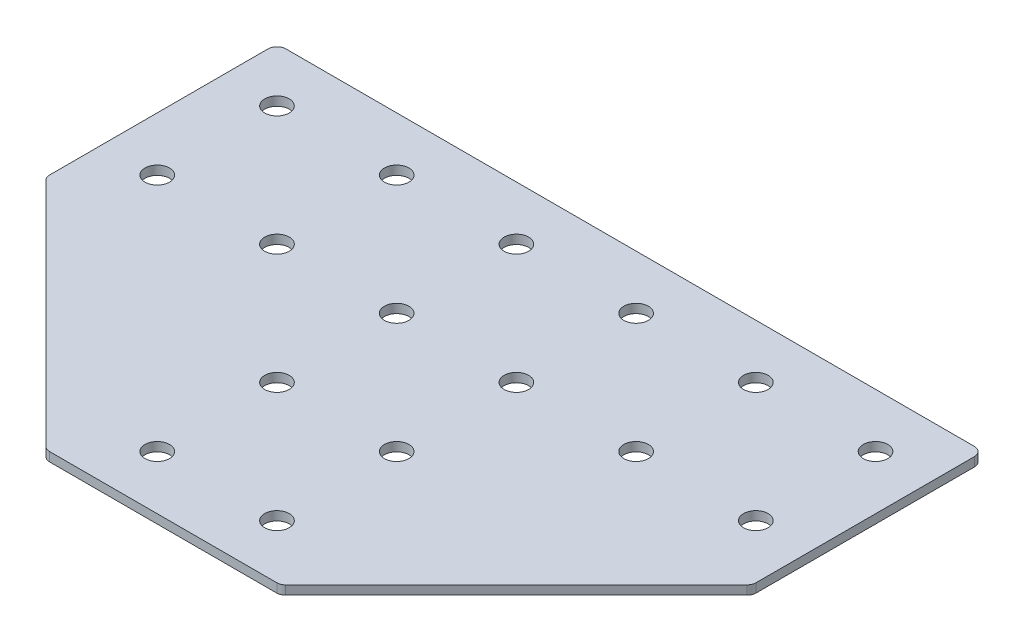
from build123d import *

# Parameters (mm, degrees)
SKETCH_1_R      = 4.1
EXTRUDE_1_DEPTH = 3


with BuildPart() as part:
    # Эскиз1 → Бобышка-Вытянуть1 (new body)
    with BuildSketch(Plane.XZ.offset(-0.99134831)):
        with BuildLine():
            Line((36.958930758, 76.479058001), (-38.898933619, 76.479058001))
            ThreePointArc((-38.898933619, 76.479058001), (-40.046983916, 76.250696599), (-41.020253962, 75.600378345))
            Line((-41.020253962, 75.600378345), (-118.091321774, -1.470689467))
            ThreePointArc((-118.091321774, -1.470689467), (-118.741640028, -2.443959513), (-118.970001431, -3.592009811))
            Line((-118.970001431, -3.592009811), (-118.970001431, -76.520941999))
            ThreePointArc((-118.970001431, -76.520941999), (-118.091321774, -78.642262342), (-115.970001431, -79.520941999))
            Line((-115.970001431, -79.520941999), (114.029998569, -79.520941999))
            ThreePointArc((114.029998569, -79.520941999), (116.151318913, -78.642262342), (117.029998569, -76.520941999))
            Line((117.029998569, -76.520941999), (117.029998569, -3.592009811))
            ThreePointArc((117.029998569, -3.592009811), (116.801637167, -2.443959513), (116.151318913, -1.470689467))
            Line((116.151318913, -1.470689467), (39.080251101, 75.600378345))
            ThreePointArc((39.080251101, 75.600378345), (38.106981055, 76.250696599), (36.958930758, 76.479058001))
        make_face()
        with Locations(Location((99.029998569, -21.520941999, 0), (0, 0, 90))):  # turned: the seam where the file's is
            Circle(SKETCH_1_R, mode=Mode.SUBTRACT)
        with Locations(Location((59.029998569, -21.520941999, 0), (0, 0, 90))):  # turned: the seam where the file's is
            Circle(SKETCH_1_R, mode=Mode.SUBTRACT)
        with Locations(Location((19.029998569, 58.479058001, 0), (0, 0, 90))):  # turned: the seam where the file's is
            Circle(SKETCH_1_R, mode=Mode.SUBTRACT)
        with Locations(Location((19.029998569, 18.479058001, 0), (0, 0, 90))):  # turned: the seam where the file's is
            Circle(SKETCH_1_R, mode=Mode.SUBTRACT)
        with Locations(Location((19.029998569, -21.520941999, 0), (0, 0, 90))):  # turned: the seam where the file's is
            Circle(SKETCH_1_R, mode=Mode.SUBTRACT)
        with Locations(Location((99.029998569, -61.520941999, 0), (0, 0, 90))):  # turned: the seam where the file's is
            Circle(SKETCH_1_R, mode=Mode.SUBTRACT)
        with Locations(Location((59.029998569, -61.520941999, 0), (0, 0, 90))):  # turned: the seam where the file's is
            Circle(SKETCH_1_R, mode=Mode.SUBTRACT)
        with Locations(Location((19.029998569, -61.520941999, 0), (0, 0, 90))):  # turned: the seam where the file's is
            Circle(SKETCH_1_R, mode=Mode.SUBTRACT)
        with Locations(Location((-100.970001431, -21.520941999, 0), (0, 0, 90))):  # turned: the seam where the file's is
            Circle(SKETCH_1_R, mode=Mode.SUBTRACT)
        with Locations(Location((-60.970001431, -21.520941999, 0), (0, 0, 90))):  # turned: the seam where the file's is
            Circle(SKETCH_1_R, mode=Mode.SUBTRACT)
        with Locations(Location((-20.970001431, 58.479058001, 0), (0, 0, 90))):  # turned: the seam where the file's is
            Circle(SKETCH_1_R, mode=Mode.SUBTRACT)
        with Locations(Location((-20.970001431, 18.479058001, 0), (0, 0, 90))):  # turned: the seam where the file's is
            Circle(SKETCH_1_R, mode=Mode.SUBTRACT)
        with Locations(Location((-20.970001431, -21.520941999, 0), (0, 0, 90))):  # turned: the seam where the file's is
            Circle(SKETCH_1_R, mode=Mode.SUBTRACT)
        with Locations(Location((-100.970001431, -61.520941999, 0), (0, 0, 90))):  # turned: the seam where the file's is
            Circle(SKETCH_1_R, mode=Mode.SUBTRACT)
        with Locations(Location((-60.970001431, -61.520941999, 0), (0, 0, 90))):  # turned: the seam where the file's is
            Circle(SKETCH_1_R, mode=Mode.SUBTRACT)
        with Locations(Location((-20.970001431, -61.520941999, 0), (0, 0, 90))):  # turned: the seam where the file's is
            Circle(SKETCH_1_R, mode=Mode.SUBTRACT)
    extrude(amount=-EXTRUDE_1_DEPTH)


solid = part.part
